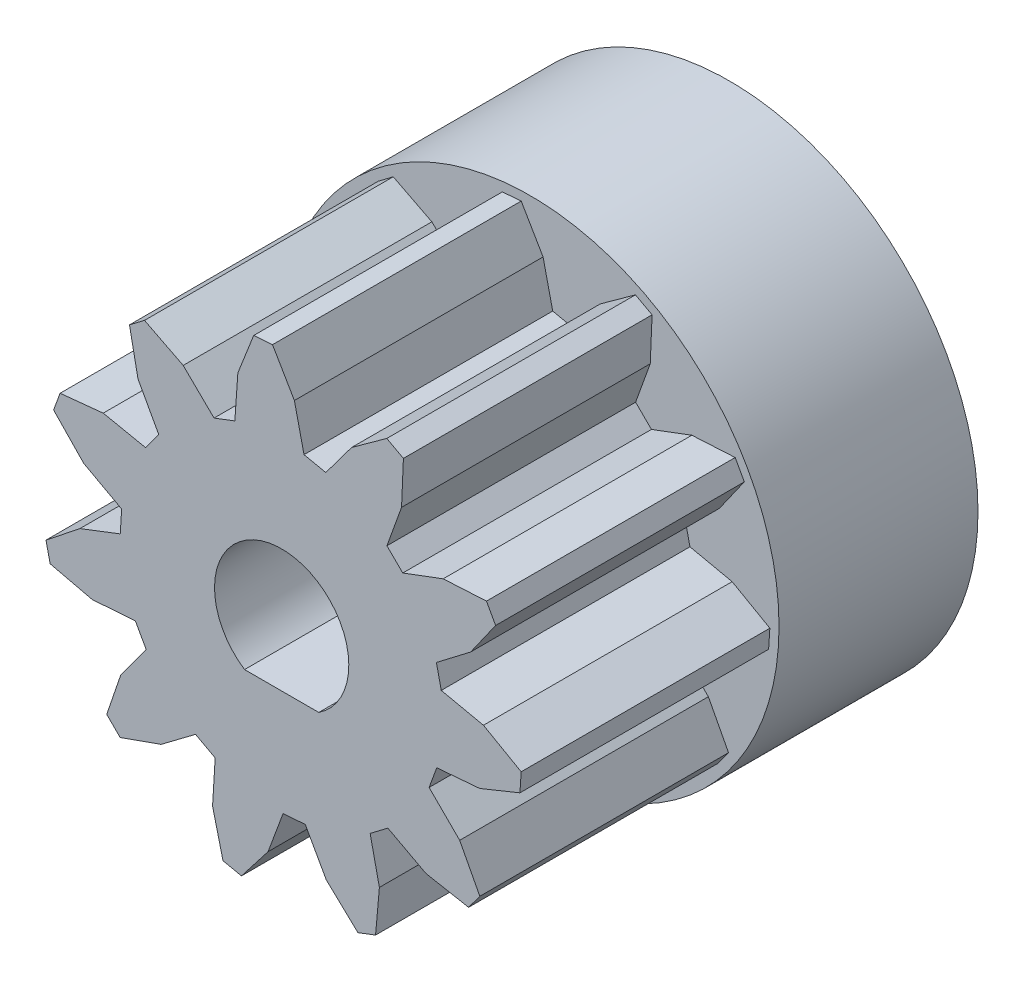
from build123d import *

# Parameters (mm, degrees)
BOSS_EXTRUDE3_DEPTH     = 10
BOSS_EXTRUDE4_START     = 8
SKETCH3_R               = 10
BOSS_EXTRUDE4_DEPTH     = 8
CUT_EXTRUDE2_DEPTH      = 2
CUT_EXTRUDE2_DEPTH_BACK = 35.997647024
SKETCH7_R               = 1.7
SKETCH8_W               = 6
SKETCH8_H               = 3
CUT_EXTRUDE3_DEPTH      = 6.8


with BuildPart() as part:
    # Sketch1 → Boss-Extrude3 (new body)
    with BuildSketch(Plane.XY):
        Polygon((16.278404236, 26.406692505), (15.44379425, 27.927993774), (15.101806641, 29.638374329), (15.70716095, 30.097465515), (17.261032104, 29.306182861), (18.501731873, 28.092857361), (19.338500977, 28.410926819), (19.458862305, 30.141960144), (20.095863342, 31.765708923), (20.85332489, 31.824638367), (21.732727051, 30.318885803), (22.120491028, 28.62739563), (22.996398926, 28.442581177), (24.03351593, 29.833747864), (25.447257996, 30.85533905), (26.116333008, 30.495407104), (26.042068481, 28.753242493), (25.453788757, 27.120628357), (26.09072876, 26.491607666), (27.715324402, 27.101219177), (29.456954956, 27.196311951), (29.82522583, 26.531791687), (28.820861816, 25.106338501), (27.443313599, 24.050941467), (27.639060974, 23.17742157), (29.335342407, 22.811935425), (30.851913452, 21.950332642), (30.802444458, 21.192199707), (29.18686676, 20.53603363), (27.45741272, 20.392944336), (27.14982605, 19.552253723), (28.379226685, 18.327713013), (29.189224243, 16.782974243), (28.737739563, 16.171928406), (27.023872375, 16.493377686), (25.491607666, 17.308013916), (24.778335571, 16.767074585), (25.150535583, 15.072257996), (24.996803284, 13.334815979), (24.286636353, 13.064868927), (23.018630981, 14.261878967), (22.170021057, 15.775596619), (21.277534485, 15.70615387), (20.674362183, 14.079162598), (19.605697632, 12.700645447), (18.862319946, 12.857494354), (18.442756653, 14.550018311), (18.54724884, 16.282234192), (17.758888245, 16.706329346), (16.37184906, 15.663711548), (14.727554321, 15.081794739), (14.186981201, 15.615646362), (14.749069214, 17.266319275), (15.773483276, 18.667060852), (15.339553833, 19.450050354), (13.609024048, 19.32283783), (11.911148071, 19.722267151), (11.745010376, 20.463630676), (13.110290527, 21.548377991), (14.729377747, 22.172920227), (14.787651062, 23.066207886), (13.263061523, 23.89478302), (12.05065918, 25.148750305), (12.311706543, 25.862243652), (14.046714783, 26.03666687), (15.746429443, 25.686714172), align=None)
        with BuildLine():
            Line((19.728870468, 19.947937012), (22.713832779, 19.947937012))
            ThreePointArc((22.713832779, 19.947937012), (21.221351624, 24.897937012), (19.728870468, 19.947937012))
        make_face(mode=Mode.SUBTRACT)
    extrude(amount=BOSS_EXTRUDE3_DEPTH)

    # Sketch3 → Boss-Extrude4 (add)
    with BuildSketch(Plane(origin=(0, 0, 0), x_dir=(-1, 0, 0), z_dir=(0, 0, -1)).offset(BOSS_EXTRUDE4_START)):
        with Locations((-21.221351624, 22.197937012)):
            Circle(SKETCH3_R)
        with BuildLine():
            Line((-19.728870468, 19.947937012), (-22.713832779, 19.947937012))
            ThreePointArc((-22.713832779, 19.947937012), (-21.221351624, 24.897937012), (-19.728870468, 19.947937012))
        make_face(mode=Mode.SUBTRACT)
    extrude(amount=-BOSS_EXTRUDE4_DEPTH)

    # Sketch7 → Cut-Extrude2 (cut, two sides: drawn at the far end of the back side and taken through both)
    with BuildSketch(Plane(origin=(0, 19.947937012, 0), x_dir=(1, 0, 0), z_dir=(0, 1, 0)).offset(-CUT_EXTRUDE2_DEPTH_BACK)):
        with Locations((21.221351624, 4.6)):
            Circle(SKETCH7_R)
    extrude(amount=CUT_EXTRUDE2_DEPTH + CUT_EXTRUDE2_DEPTH_BACK, mode=Mode.SUBTRACT)

    # Sketch8 → Cut-Extrude3 (cut)
    with BuildSketch(Plane(origin=(0, 0, -8), x_dir=(-1, 0, 0), z_dir=(0, 0, -1))):
        with Locations((-21.221351624, 17.197937012)):
            Rectangle(SKETCH8_W, SKETCH8_H)
    extrude(amount=-CUT_EXTRUDE3_DEPTH, mode=Mode.SUBTRACT)


solid = part.part
